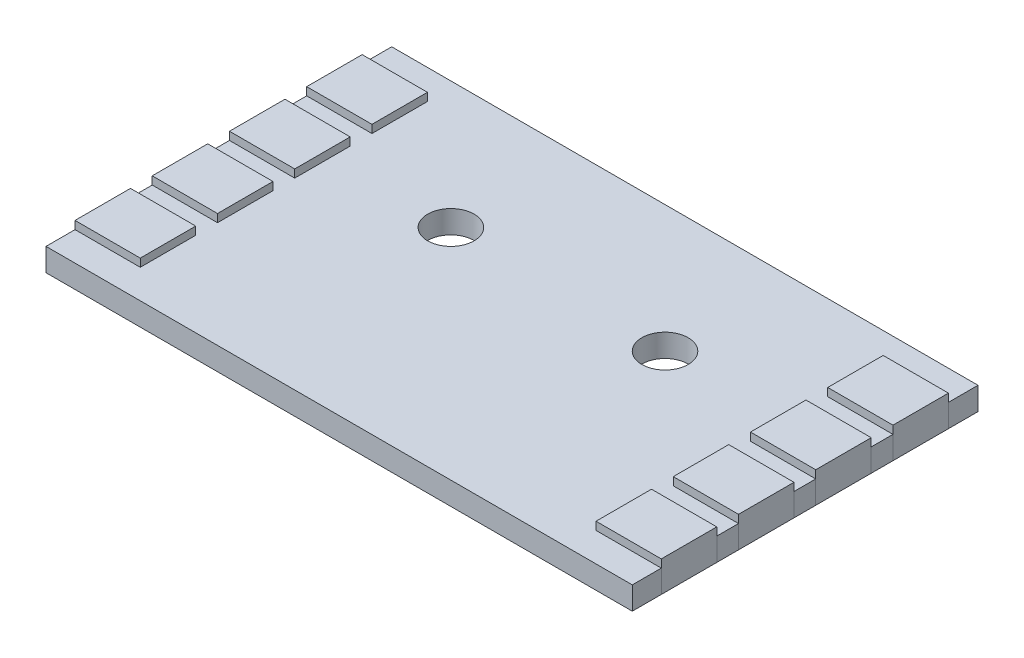
from build123d import *

# Parameters (mm, degrees)
SKETCH1_R             = 1.6256
BOSS_EXTRUDE1_DEPTH   = 1.6
SKETCH1_3_W           = 4.572
SKETCH1_3_H           = 3.8862
BOSS_EXTRUDE2_DEPTH   = 2.159
BOSS_EXTRUDE2_2_DEPTH = 2.159
BOSS_EXTRUDE2_3_DEPTH = 2.159
BOSS_EXTRUDE2_4_DEPTH = 2.159
BOSS_EXTRUDE2_5_DEPTH = 2.159
BOSS_EXTRUDE2_6_DEPTH = 2.159
BOSS_EXTRUDE2_7_DEPTH = 2.159
BOSS_EXTRUDE2_8_DEPTH = 2.159


with BuildPart() as part:
    # Sketch1 → Boss-Extrude1 (new body)
    with BuildSketch(Plane(origin=(0, 0, 0), x_dir=(1, 0, 0), z_dir=(0, 1, 0))):
        Polygon((41.0718, -18.3007), (41.0718, -16.7767), (36.4998, -16.7767), (36.4998, -12.8905), (41.0718, -12.8905), (41.0718, -11.3665), (36.4998, -11.3665), (36.4998, -7.4803), (41.0718, -7.4803), (41.0718, -5.9563), (36.4998, -5.9563), (36.4998, -2.0701), (41.0718, -2.0701), (41.0718, 0), (0, 0), (0, -2.0701), (4.572, -2.0701), (4.572, -5.9563), (0, -5.9563), (0, -7.4803), (4.572, -7.4803), (4.572, -11.3665), (0, -11.3665), (0, -12.8905), (4.572, -12.8905), (4.572, -16.7767), (0, -16.7767), (0, -18.3007), (4.572, -18.3007), (4.572, -22.1869), (0, -22.1869), (0, -24.2189), (41.0718, -24.2189), (41.0718, -22.1869), (36.4998, -22.1869), (36.4998, -18.3007), align=None)
        with Locations((28.0359, -8.89)):
            Circle(SKETCH1_R, mode=Mode.SUBTRACT)
        with Locations((13.0359, -8.89)):
            Circle(SKETCH1_R, mode=Mode.SUBTRACT)
    extrude(amount=BOSS_EXTRUDE1_DEPTH)


with BuildPart() as body_2:
    # Sketch1_3 → Boss-Extrude2 (new body)
    with BuildSketch(Plane(origin=(0, 0, 0), x_dir=(1, 0, 0), z_dir=(0, 1, 0))):
        with Locations((38.7858, -14.8336)):
            Rectangle(SKETCH1_3_W, SKETCH1_3_H)
    extrude(amount=BOSS_EXTRUDE2_DEPTH)


with BuildPart() as body_3:
    # Sketch1_3 → Boss-Extrude2 2 (new body)
    with BuildSketch(Plane(origin=(0, 0, 0), x_dir=(1, 0, 0), z_dir=(0, 1, 0))):
        with Locations((38.7858, -20.2438)):
            Rectangle(SKETCH1_3_W, SKETCH1_3_H)
    extrude(amount=BOSS_EXTRUDE2_2_DEPTH)


with BuildPart() as body_4:
    # Sketch1_3 → Boss-Extrude2 3 (new body)
    with BuildSketch(Plane(origin=(0, 0, 0), x_dir=(1, 0, 0), z_dir=(0, 1, 0))):
        with Locations((38.7858, -9.4234)):
            Rectangle(SKETCH1_3_W, SKETCH1_3_H)
    extrude(amount=BOSS_EXTRUDE2_3_DEPTH)


with BuildPart() as body_5:
    # Sketch1_3 → Boss-Extrude2 4 (new body)
    with BuildSketch(Plane(origin=(0, 0, 0), x_dir=(1, 0, 0), z_dir=(0, 1, 0))):
        with Locations((38.7858, -4.0132)):
            Rectangle(SKETCH1_3_W, SKETCH1_3_H)
    extrude(amount=BOSS_EXTRUDE2_4_DEPTH)


with BuildPart() as body_6:
    # Sketch1_3 → Boss-Extrude2 5 (new body)
    with BuildSketch(Plane(origin=(0, 0, 0), x_dir=(1, 0, 0), z_dir=(0, 1, 0))):
        with Locations((2.286, -20.2438)):
            Rectangle(SKETCH1_3_W, SKETCH1_3_H)
    extrude(amount=BOSS_EXTRUDE2_5_DEPTH)


with BuildPart() as body_7:
    # Sketch1_3 → Boss-Extrude2 6 (new body)
    with BuildSketch(Plane(origin=(0, 0, 0), x_dir=(1, 0, 0), z_dir=(0, 1, 0))):
        with Locations((2.286, -14.8336)):
            Rectangle(SKETCH1_3_W, SKETCH1_3_H)
    extrude(amount=BOSS_EXTRUDE2_6_DEPTH)


with BuildPart() as body_8:
    # Sketch1_3 → Boss-Extrude2 7 (new body)
    with BuildSketch(Plane(origin=(0, 0, 0), x_dir=(1, 0, 0), z_dir=(0, 1, 0))):
        with Locations((2.286, -4.0132)):
            Rectangle(SKETCH1_3_W, SKETCH1_3_H)
    extrude(amount=BOSS_EXTRUDE2_7_DEPTH)


with BuildPart() as body_9:
    # Sketch1_3 → Boss-Extrude2 8 (new body)
    with BuildSketch(Plane(origin=(0, 0, 0), x_dir=(1, 0, 0), z_dir=(0, 1, 0))):
        with Locations((2.286, -9.4234)):
            Rectangle(SKETCH1_3_W, SKETCH1_3_H)
    extrude(amount=BOSS_EXTRUDE2_8_DEPTH)


solid = Compound([part.part, body_2.part, body_3.part, body_4.part, body_5.part, body_6.part, body_7.part, body_8.part, body_9.part])
